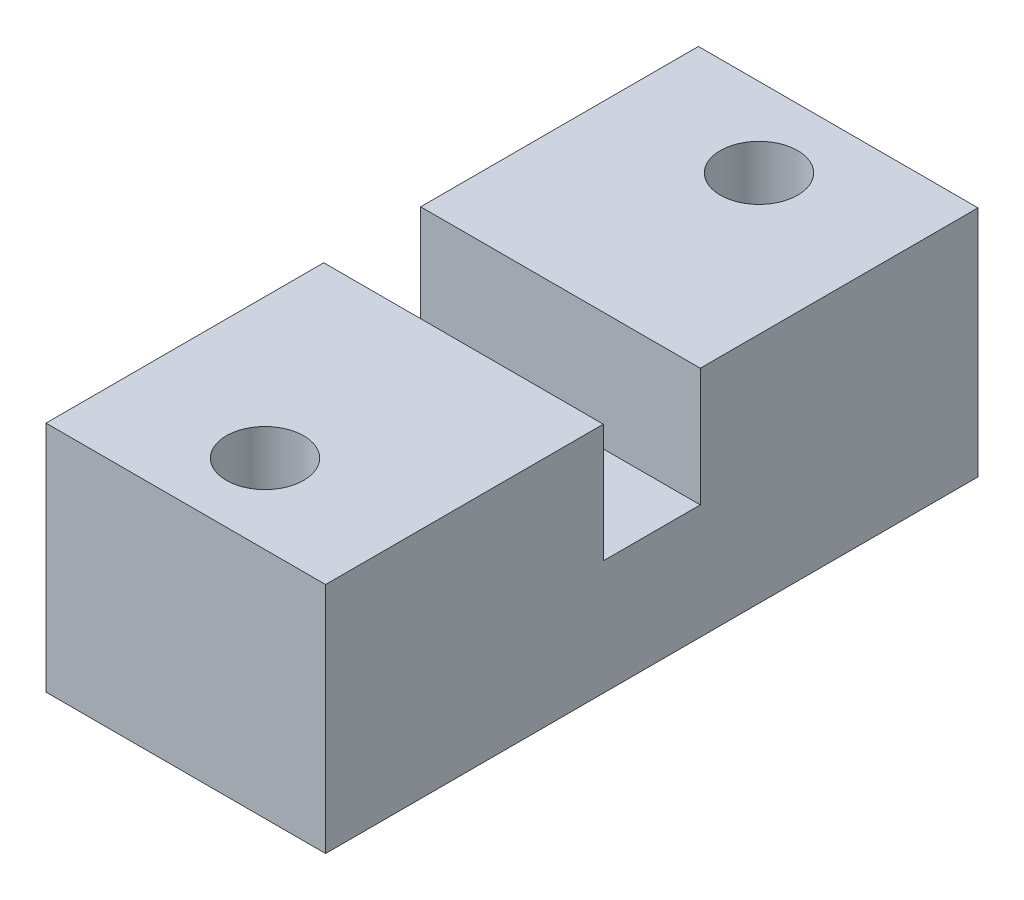
from build123d import *

# Parameters (mm, degrees)
SKETCH1_W             = 30
SKETCH1_H             = 70
BOSS_EXTRUDE1_DEPTH   = 25
SKETCH2_W             = 30
SKETCH2_H             = 10.4
CUT_EXTRUDE1_DEPTH    = 12.7
SKETCH3_R             = 4.15
CUT_EXTRUDE2_DEPTH    = 26
CHAMFER1_SIZE         = 1
CHAMFER1_SIZE2        = 1.191753593
CHAMFER1_PART_2_SIZE  = 1
CHAMFER1_PART_2_SIZE2 = 1.191753593


with BuildPart() as part:
    # Sketch1 → Boss-Extrude1 (new body)
    with BuildSketch(Plane(origin=(0, 0, 0), x_dir=(1, 0, 0), z_dir=(0, 1, 0))):
        Rectangle(SKETCH1_W, SKETCH1_H)
    extrude(amount=BOSS_EXTRUDE1_DEPTH)

    # Sketch2 → Cut-Extrude1 (cut)
    with BuildSketch(Plane(origin=(0, 25, 0), x_dir=(1, 0, 0), z_dir=(0, 1, 0))):
        Rectangle(SKETCH2_W, SKETCH2_H)
    extrude(amount=-CUT_EXTRUDE1_DEPTH, mode=Mode.SUBTRACT)

    # Sketch3 → Cut-Extrude2 (cut, through all)
    with BuildSketch(Plane(origin=(0, 25, 0), x_dir=(1, 0, 0), z_dir=(0, 1, 0))):
        with Locations((0, 26.5)):
            Circle(SKETCH3_R)
        with Locations((0, -26.5)):
            Circle(SKETCH3_R)
    extrude(amount=-CUT_EXTRUDE2_DEPTH, mode=Mode.SUBTRACT)

    # Chamfer1
    chamfer1_edges = [part.edges().sort_by_distance(p)[0] for p in [
        (-4.15, 0, -26.5),
    ]]
    chamfer1_side = [part.faces().sort_by_distance(p)[0] for p in [
        (-4.15, 12.5, -26.5),
    ]]
    chamfer(chamfer1_edges, length=CHAMFER1_SIZE, length2=CHAMFER1_SIZE2, reference=chamfer1_side[0])

    # Chamfer1 part 2
    chamfer1_part_2_edges = [part.edges().sort_by_distance(p)[0] for p in [
        (-4.15, 0, 26.5),
    ]]
    chamfer1_part_2_side = [part.faces().sort_by_distance(p)[0] for p in [
        (-4.15, 12.5, 26.5),
    ]]
    chamfer(chamfer1_part_2_edges, length=CHAMFER1_PART_2_SIZE, length2=CHAMFER1_PART_2_SIZE2, reference=chamfer1_part_2_side[0])


solid = part.part
